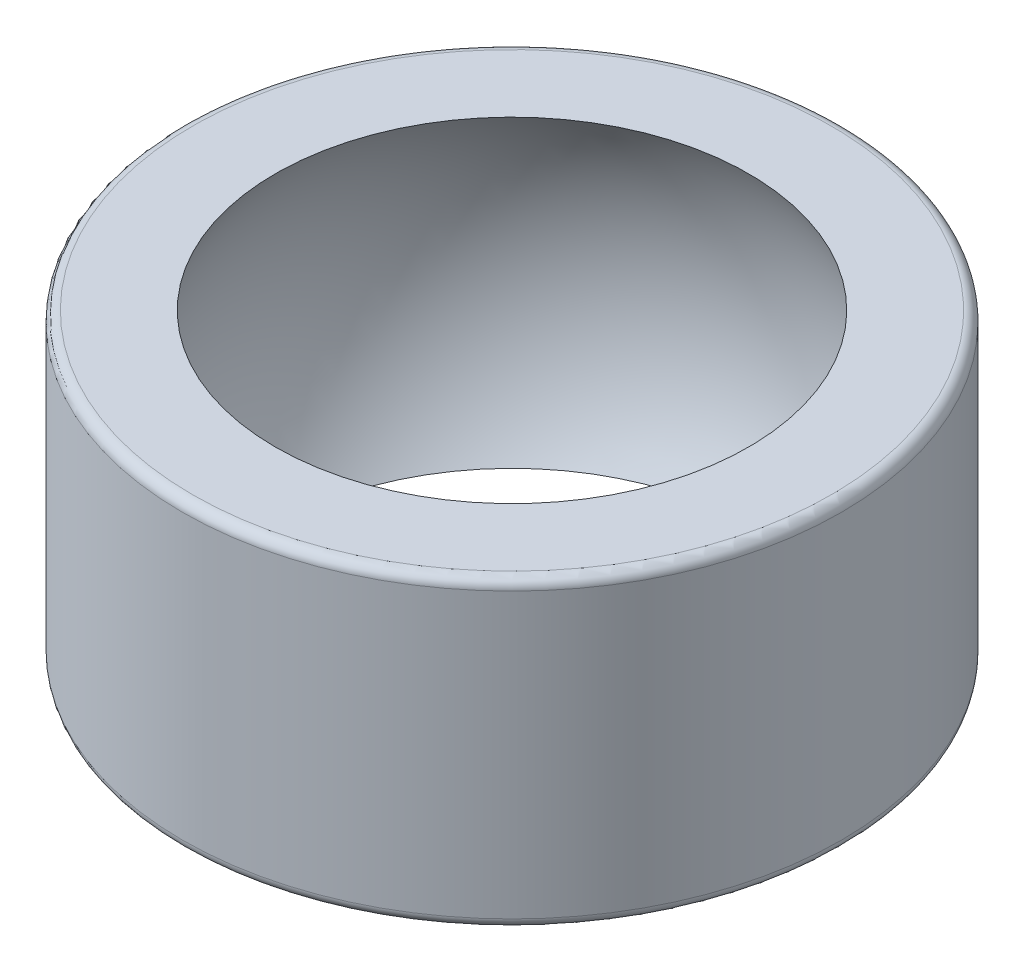
from build123d import *

# Parameters (mm, degrees)
SZKIC1_R                    = 6.5
DODANIE_WYCI_GNI_CIE1_DEPTH = 3
ZAOKR_GLENIE1_R             = 0.2


with BuildPart() as part:
    # Szkic1 → Dodanie-wyciągnięcie1 (new body, symmetric)
    with BuildSketch(Plane(origin=(0, 0, 0), x_dir=(1, 0, 0), z_dir=(0, 1, 0))):
        Circle(SZKIC1_R)
    extrude(amount=DODANIE_WYCI_GNI_CIE1_DEPTH, both=True)

    # Szkic3 → Wycięcie-obrót1 (revolve, cut)
    with BuildSketch(Plane.XY):
        with BuildLine():
            Line((0, -5.55), (0, 5.55))
            ThreePointArc((0, 5.55), (5.55, 0), (0, -5.55))
        make_face()
    revolve(axis=Axis((0, -5.55, 0), (0, 1, 0)), mode=Mode.SUBTRACT)

    # Zaokrąglenie1
    zaokr_glenie1_edges = [part.edges().sort_by_distance(p)[0] for p in [
        (-6.5, -3, 0),
        (-6.5, 3, 0),
    ]]
    fillet(zaokr_glenie1_edges, radius=ZAOKR_GLENIE1_R)


solid = part.part
